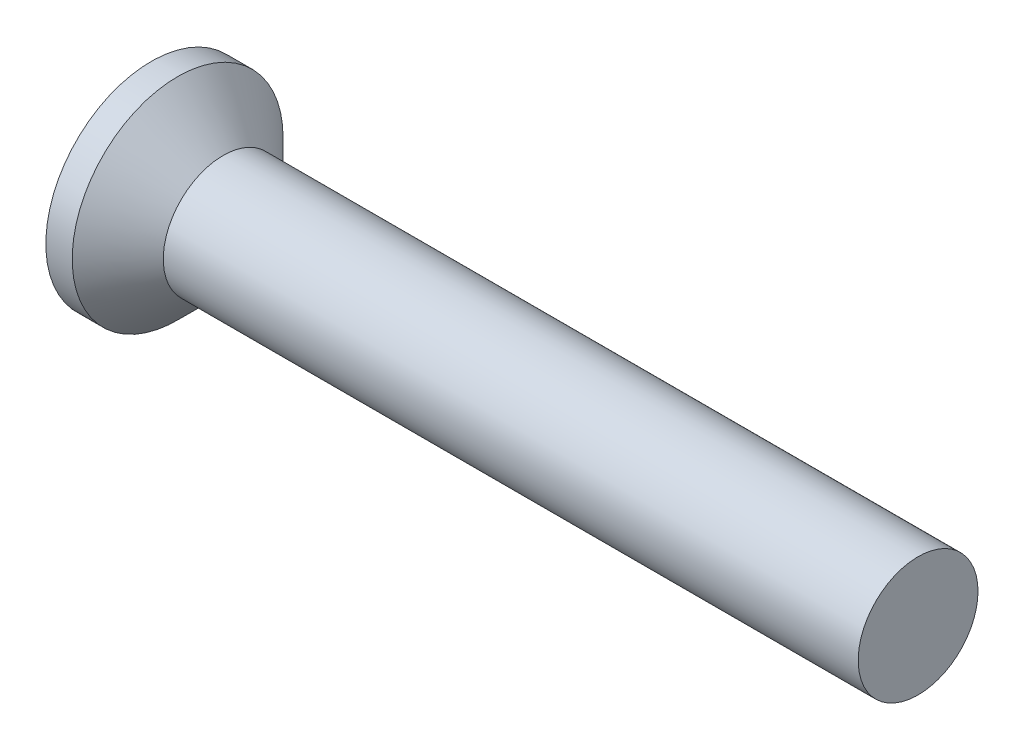
from build123d import *

# Parameters (mm, degrees)
CROSSRECESS_DEPTH = 0.75
DRAFT9_ANGLE      = 30
FILLET5_R         = 0.3
SKETCH10_W        = 0.45
SKETCH10_H        = 1.25


with BuildPart() as part:
    # Sketch1 → Base (revolve)
    with BuildSketch(Plane.XY):
        Polygon((16, 1.25), (2.4, 1.25), (1.5, 1.25), (0.55, 2.2), (0, 2.2), (0, 0), (16, 0), align=None)
    revolve(axis=Axis((4.515812911, 0, 0), (-1, 0, 0)))

    # Sketch6 → CrossRecess (cut)
    with BuildSketch(Plane(origin=(0, 0, 0), x_dir=(0, 0, -1), z_dir=(1, 0, 0))):
        Polygon((0.29, 0.29), (0.29, 1.45), (-0.29, 1.45), (-0.29, 0.29), (-1.45, 0.29), (-1.45, -0.29), (-0.29, -0.29), (-0.29, -1.45), (0.29, -1.45), (0.29, -0.29), (1.45, -0.29), (1.45, 0.29), align=None)
    extrude(amount=CROSSRECESS_DEPTH, mode=Mode.SUBTRACT)

    # Draft9
    draft9_faces = [part.faces().sort_by_distance(p)[0] for p in [
        (0.375, -1.45, 0),
        (0.375, 0, 1.45),
        (0.375, 0, -1.45),
        (0.375, 1.45, 0),
    ]]
    draft(draft9_faces, Plane(origin=(0, 2.2, 0), x_dir=(0, 0, -1), z_dir=(-1, 0, 0)), DRAFT9_ANGLE)

    # Fillet5
    fillet5_edges = [part.edges().sort_by_distance(p)[0] for p in [
        (0.375, 0.29, 0.29),
        (0.375, -0.29, 0.29),
        (0.375, -0.29, -0.29),
        (0.375, 0.29, -0.29),
    ]]
    fillet(fillet5_edges, radius=FILLET5_R)

    # Sketch10 → Revolve2 (revolve)
    with BuildSketch(Plane.XY):
        with Locations((1.725, 0.625)):
            Rectangle(SKETCH10_W, SKETCH10_H)
    revolve(axis=Axis((62.228915663, 0, 0), (-1, 0, 0)))


solid = part.part
